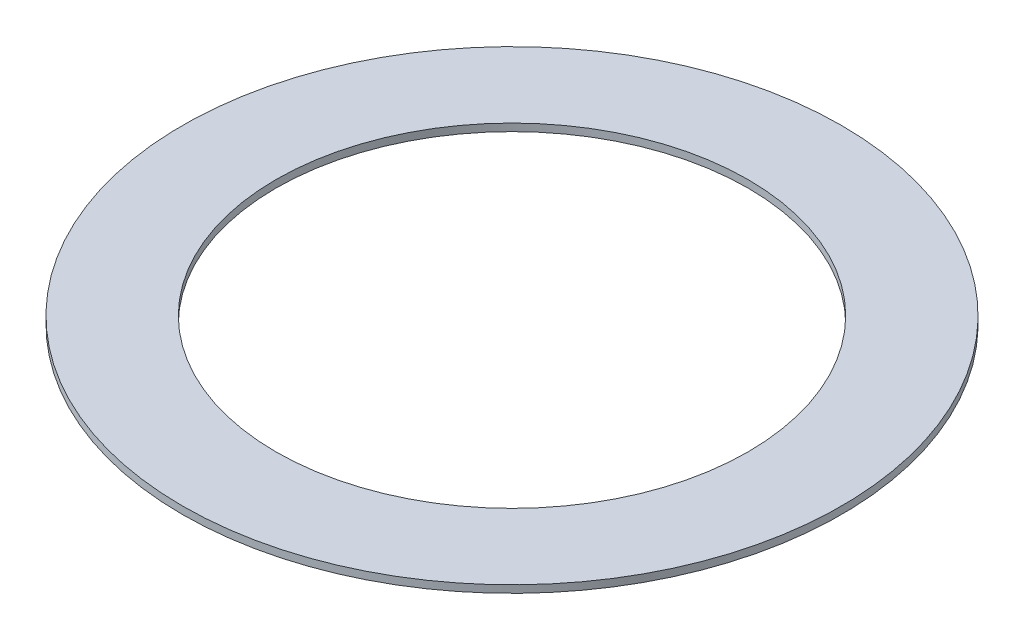
from build123d import *

# Parameters (mm, degrees)
SKETCH1_R           = 106.426
SKETCH1_R_2         = 76.2
BOSS_EXTRUDE1_DEPTH = 2.4


with BuildPart() as part:
    # Sketch1 → Boss-Extrude1 (new body)
    with BuildSketch(Plane(origin=(0, 0, 0), x_dir=(1, 0, 0), z_dir=(0, 1, 0))):
        Circle(SKETCH1_R)
        Circle(SKETCH1_R_2, mode=Mode.SUBTRACT)
    extrude(amount=BOSS_EXTRUDE1_DEPTH)


solid = part.part
